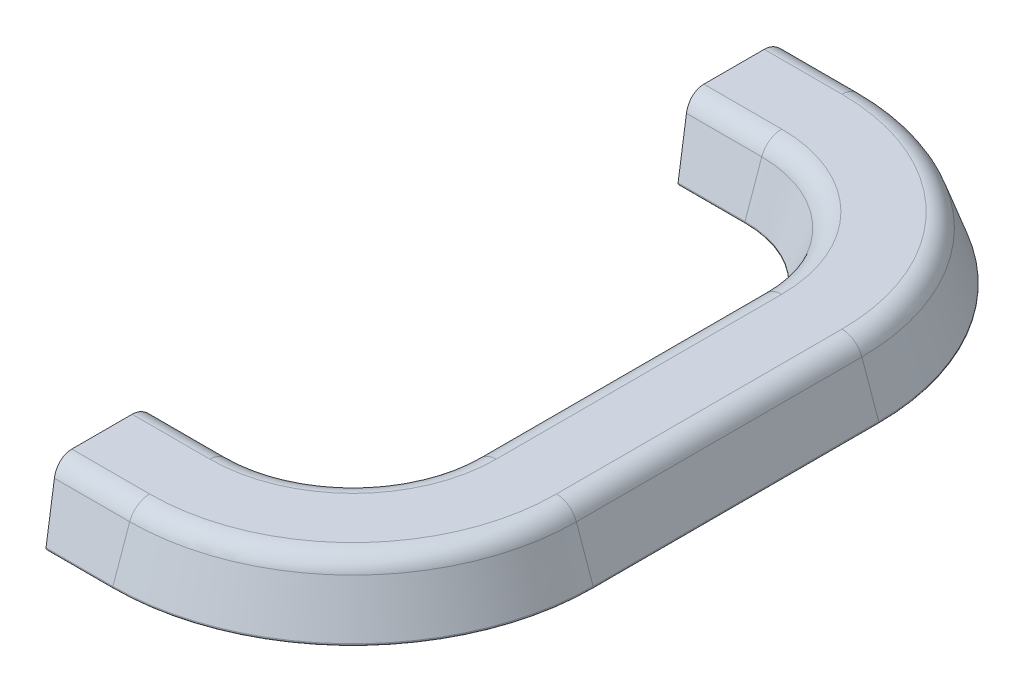
from build123d import *

# Parameters (mm, degrees)
FILLET1_R      = 5.08
SHELL1_T       = -2.54
EXTRUDE1_REACH = 121.17
FILLET2_R      = 0.396875


with BuildPart() as part:
    # Sweep1: sweep along a path in Sketch2
    with BuildLine(Plane(origin=(0, 0, 0), x_dir=(1, 0, 0), z_dir=(0, 1, 0))) as sweep1_path:
        Line((0, -59.724007387), (18.701415201, -59.724007387))
        ThreePointArc((18.701415201, -59.724007387), (36.661927443, -52.284519629), (44.101415201, -34.324007387))
        Line((44.101415201, -34.324007387), (44.101415201, 34.324007387))
        ThreePointArc((44.101415201, 34.324007387), (36.661927443, 52.284519629), (18.701415201, 59.724007387))
        Line((18.701415201, 59.724007387), (0, 59.724007387))
    # Sketch1 → Sweep1 (sweep)
    with BuildSketch(Plane(origin=(0, 0, 0), x_dir=(0, 0, -1), z_dir=(1, 0, 0))):
        Polygon((-92.230378578, 0), (-59.724007387, 0), (-65.134510769, 15.350234506), (-86.819875195, 15.350234506), align=None)
    sweep(path=sweep1_path.line)

    # SurfaceCut1
    split(bisect_by=Plane(origin=(2.625044703, 0.462866207, 0), x_dir=(0, 0, 1), z_dir=(-0.9848077530122041, -0.17364817766695276, 0)), keep=Keep.BOTTOM)

    # Fillet1
    fillet1_edges = [part.edges().sort_by_distance(p)[0] for p in [
        (55.821599313, 15.350234506, 71.444191499),
        (40.487731075, 15.350234506, 56.11032326),
        (71.19728301, 15.350234506, 0),
        (49.511918584, 15.350234506, 0),
        (55.821599313, 15.350234506, -71.444191499),
        (40.487731075, 15.350234506, -56.11032326),
        (9.350707601, 15.350234506, -86.819875195),
        (9.350707601, 15.350234506, -65.134510769),
        (9.350707601, 15.350234506, 86.819875195),
        (9.350707601, 15.350234506, 65.134510769),
    ]]
    fillet(fillet1_edges, radius=FILLET1_R)

    # Shell1
    shell1_openings = [part.faces().sort_by_distance(p)[0] for p in [
        (45.698397314, 0, 0),
        (1.458578097, 7.07822706, -75.977192982),
        (1.458578097, 7.07822706, 75.977192982),
    ]]
    offset(amount=SHELL1_T, openings=shell1_openings, kind=Kind.INTERSECTION)

    # Sketch4 → Extrude1 (add, up to next)
    with BuildSketch(Plane(origin=(2.625044703, 0.462866207, 0), x_dir=(0, 0, 1), z_dir=(-0.9848077530122041, -0.1736481776669528, 0)), mode=Mode.PRIVATE) as extrude1_sk1:
        with BuildLine():
            Line((-78.948196177, 12.537846358), (-78.59959728, 8.553342733))
            ThreePointArc((-78.59959728, 8.553342733), (-75.977192982, 6.150351924), (-73.354788685, 8.553342733))
            Line((-73.354788685, 8.553342733), (-73.006189788, 12.537846358))
            Line((-73.006189788, 12.537846358), (-78.948196177, 12.537846358))
        make_face()
    extrude1_tool1 = extrude(extrude1_sk1.sketch, amount=-EXTRUDE1_REACH, mode=Mode.PRIVATE) - part.part
    extrude1 = extrude1_tool1.solids().sort_by_distance((0.946808, 9.980618, -75.977193))[0]
    add(extrude1)

    # Sketch5 → 7_64 _0.10938_ Diameter Hole1 (revolve, cut)
    with BuildSketch(Plane(origin=(1.099932111, 9.112209524, -75.977192982), x_dir=(0.1736481776669528, -0.9848077530122041, 0), z_dir=(0, 0, 1))):
        Polygon((0, 0), (0, 13.534671108), (1.389126, 12.7), (1.389126, 0), align=None)
    f_7_64_0_10938_diameter_hole1 = revolve(axis=Axis((-5.153597121, 8.009543596, -75.977192982), (0.9848077530122041, 0.17364817766695284, 0)), mode=Mode.SUBTRACT)

    # Mirror1: Extrude1, 7_64 _0.10938_ Diameter Hole1 across plane
    add(extrude1.mirror(Plane.XY))
    add(f_7_64_0_10938_diameter_hole1.mirror(Plane.XY), mode=Mode.SUBTRACT)

    # Fillet2
    fillet2_edges = [part.edges().sort_by_distance(p)[0] for p in [
        (36.661927443, 0, 52.284519629),
        (59.647402944, 0, 75.26999513),
        (11.920791464, 12.810234506, -78.773896729),
        (11.920791464, 12.810234506, -73.180489236),
        (37.231090066, 12.810234506, -76.005795341),
        (11.920791464, 12.810234506, 78.773896729),
        (37.231090066, 12.810234506, 76.005795341),
        (11.920791464, 12.810234506, 73.180489236),
        (44.101415201, 0, 0),
        (76.607786392, 0, 0),
        (36.661927443, 0, -52.284519629),
        (59.647402944, 0, -75.26999513),
        (10.704037852, 0, -59.724007387),
        (10.704037852, 0, -92.230378578),
        (10.704037852, 0, 59.724007387),
        (10.704037852, 0, 92.230378578),
    ]]
    fillet(fillet2_edges, radius=FILLET2_R)


solid = part.part
